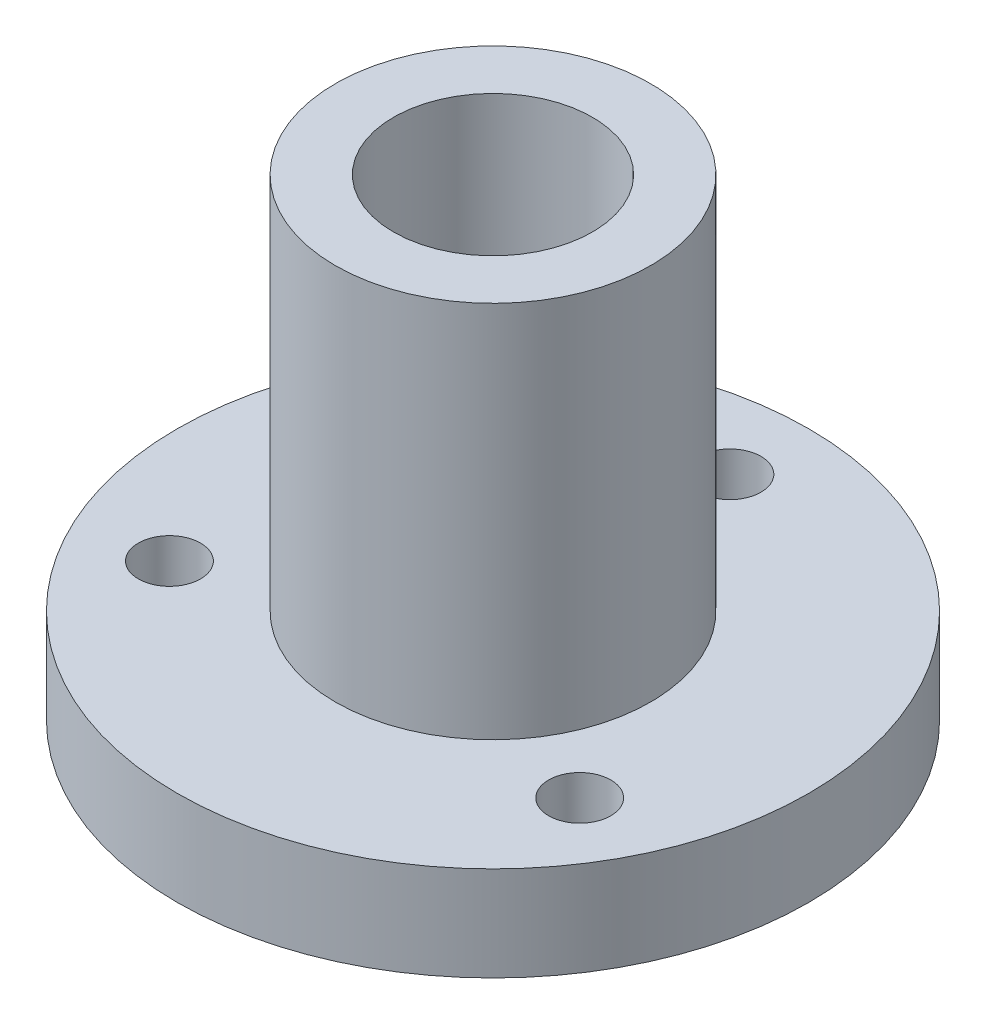
from build123d import *

# Parameters (mm, degrees)
SKETCH1_R                   = 12.7
SKETCH1_R_2                 = 4
BOSS_EXTRUDE1_DEPTH         = 3.8
SKETCH2_R                   = 6.34
SKETCH2_R_2                 = 4
BOSS_EXTRUDE2_DEPTH         = 15.2
TAP_DRILL_FOR_M3_TAP1_D     = 2.5
TAP_DRILL_FOR_M3_TAP1_DEPTH = 3.8


with BuildPart() as part:
    # Sketch1 → Boss-Extrude1 (new body)
    with BuildSketch(Plane(origin=(0, 0, 0), x_dir=(1, 0, 0), z_dir=(0, 1, 0))):
        Circle(SKETCH1_R)
        Circle(SKETCH1_R_2, mode=Mode.SUBTRACT)
    extrude(amount=BOSS_EXTRUDE1_DEPTH)

    # Sketch2 → Boss-Extrude2 (add)
    with BuildSketch(Plane(origin=(0, 3.8, 0), x_dir=(1, 0, 0), z_dir=(0, 1, 0))):
        Circle(SKETCH2_R)
        Circle(SKETCH2_R_2, mode=Mode.SUBTRACT)
    extrude(amount=BOSS_EXTRUDE2_DEPTH)

    # Tap Drill for M3 Tap1
    with Locations(Plane(origin=(-8.25, 0, 4.763139721), x_dir=(0, 0, -1), z_dir=(0, -1, 0))):
        with Locations((0, 0), (0, 16.5), (14.289419163, 8.25)):
            Hole(TAP_DRILL_FOR_M3_TAP1_D / 2, depth=TAP_DRILL_FOR_M3_TAP1_DEPTH)


solid = part.part
